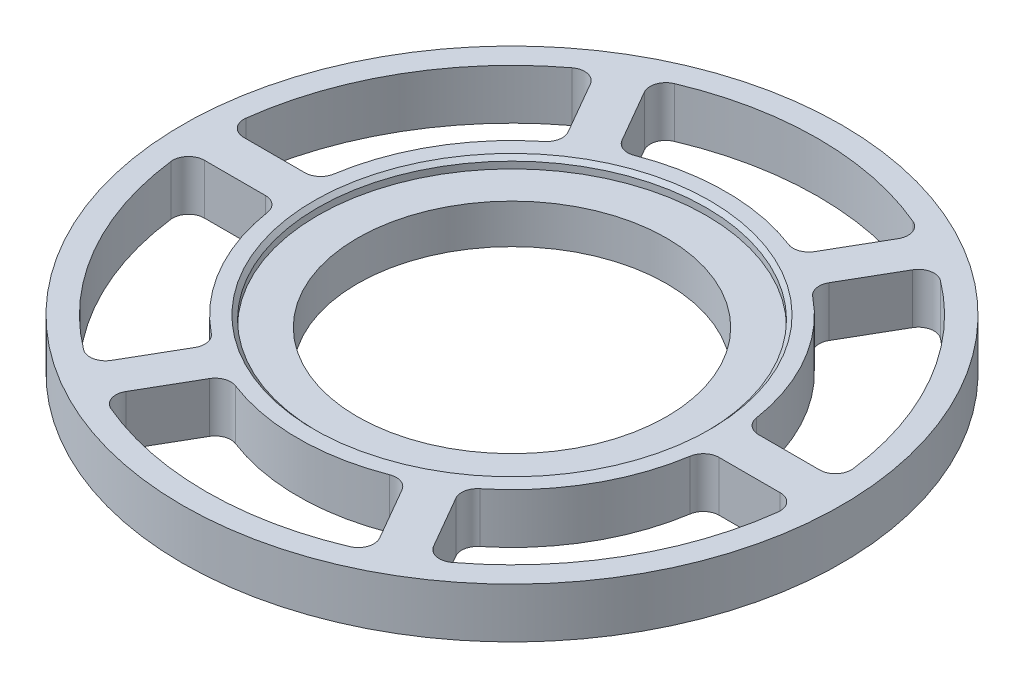
from build123d import *

# Parameters (mm, degrees)
CUT_EXTRUDE1_DEPTH       = 13.7
FILLET1_R                = 4
CIRPATTERN4_COUNT        = 6
FILLET1_OF_CIRPATTERN4_R = 4
CHAMFER1_SIZE            = 1
SKETCH9_R                = 83.55
SKETCH9_R_2              = 82.55
BOSS_EXTRUDE1_DEPTH      = 12.7


with BuildPart() as part:
    # Sketch2 → Revolve1 (revolve)
    with BuildSketch(Plane(origin=(0, 0, 0), x_dir=(0, 0, -1), z_dir=(1, 0, 0))):
        Polygon((-39.2125, 0), (-82.55, 0), (-82.55, 12.7), (-49.2125, 12.7), (-49.2125, 10), (-39.2125, 10), align=None)
    revolve(axis=Axis((0, -0.9525, 0), (0, 1, 0)))

    # Sketch8 → Cut-Extrude1 (cut, through all)
    with BuildSketch(Plane(origin=(0, 12.7, 0), x_dir=(1, 0, 0), z_dir=(0, 1, 0))):
        with BuildLine():
            Line((-34.364196, 69.520533), (-22.66059, 49.249293))
            ThreePointArc((-22.66059, 49.249293), (0, 54.2125), (22.66059, 49.249293))
            Line((22.66059, 49.249293), (34.364196, 69.520533))
            ThreePointArc((34.364196, 69.520533), (0, 77.55), (-34.364196, 69.520533))
        make_face()
    cut_extrude1 = extrude(amount=-CUT_EXTRUDE1_DEPTH, mode=Mode.SUBTRACT)

    # Fillet1
    fillet1_edges = [part.edges().sort_by_distance(p)[0] for p in [
        (22.66059, 6.35, -49.249293),
        (-22.66059, 6.35, -49.249293),
        (-34.364196, 6.35, -69.520533),
        (34.364196, 6.35, -69.520533),
    ]]
    fillet(fillet1_edges, radius=FILLET1_R)

    # CirPattern4: Cut-Extrude1 ×6 about axis
    cirpattern4_axis = Axis((0, 0, 0), (0, 1, 0))
    for i in range(1, CIRPATTERN4_COUNT):
        add(cut_extrude1.rotate(cirpattern4_axis, i * 360 / CIRPATTERN4_COUNT), mode=Mode.SUBTRACT)

    # Fillet1 of CirPattern4
    fillet1_of_cirpattern4_edges = [part.edges().sort_by_distance(p)[0] for p in [
        (-31.320844, 6.35, -44.249293),
        (-53.981433, 6.35, -5),
        (-77.388646, 6.35, -5),
        (-43.02445, 6.35, -64.520533),
        (-53.981433, 6.35, 5),
        (-31.320844, 6.35, 44.249293),
        (-43.02445, 6.35, 64.520533),
        (-77.388646, 6.35, 5),
        (-22.66059, 6.35, 49.249293),
        (22.66059, 6.35, 49.249293),
        (34.364196, 6.35, 69.520533),
        (-34.364196, 6.35, 69.520533),
        (31.320844, 6.35, 44.249293),
        (53.981433, 6.35, 5),
        (77.388646, 6.35, 5),
        (43.02445, 6.35, 64.520533),
        (53.981433, 6.35, -5),
        (31.320844, 6.35, -44.249293),
        (43.02445, 6.35, -64.520533),
        (77.388646, 6.35, -5),
    ]]
    fillet(fillet1_of_cirpattern4_edges, radius=FILLET1_OF_CIRPATTERN4_R)

    # Chamfer1
    chamfer1_edges = [part.edges().sort_by_distance(p)[0] for p in [
        (0, 12.7, -49.2125),
    ]]
    chamfer(chamfer1_edges, length=CHAMFER1_SIZE)

    # Sketch9 → Boss-Extrude1 (add)
    with BuildSketch(Plane.XZ):
        Circle(SKETCH9_R)
        Circle(SKETCH9_R_2, mode=Mode.SUBTRACT)
    extrude(amount=-BOSS_EXTRUDE1_DEPTH)


solid = part.part
